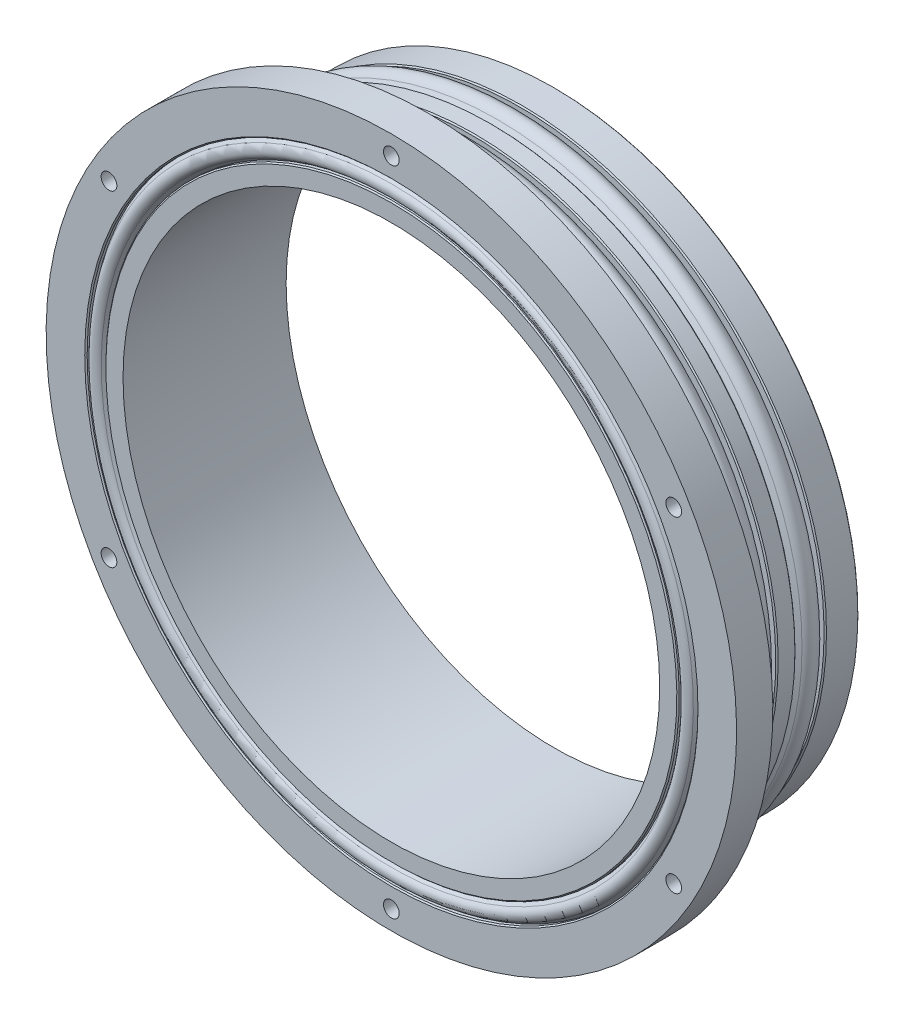
from build123d import *

# Parameters (mm, degrees)
HOLE_WIZARD_2_6_2_6_1_D     = 2.6
HOLE_WIZARD_2_6_2_6_1_DEPTH = 4
HOLE_WIZARD_2_6_2_6_2_D     = 2.6
HOLE_WIZARD_2_6_2_6_2_DEPTH = 6.526692879
HOLE_WIZARD_M80_1_D         = 88.838
HOLE_WIZARD_M80_1_DEPTH     = 27
CHAMFER_1_SIZE              = 0.2


with BuildPart() as part:
    # 草图1 → 旋转1 (revolve)
    with BuildSketch(Plane.XZ):
        with BuildLine():
            Line((47.2599, 27), (0, 27))
            Line((0, 27), (0, 0))
            Line((0, 0), (50.419, 0))
            Line((50.419, 0), (50.419, 5.587))
            Line((50.419, 5.587), (49.04105, 5.587))
            Line((49.04105, 5.587), (50.431651886, 6.547495355))
            ThreePointArc((50.431651886, 6.547495355), (51.1937, 8), (50.431651886, 9.452504645))
            Line((50.431651886, 9.452504645), (49.04105, 10.413))
            Line((49.04105, 10.413), (50.419, 10.413))
            Line((50.419, 10.413), (50.419, 13.587))
            Line((50.419, 13.587), (49.04105, 13.587))
            Line((49.04105, 13.587), (50.431651886, 14.547495355))
            ThreePointArc((50.431651886, 14.547495355), (51.1937, 16), (50.431651886, 17.452504645))
            Line((50.431651886, 17.452504645), (49.04105, 18.413))
            Line((49.04105, 18.413), (50.419, 18.413))
            Line((50.419, 18.413), (50.419, 21))
            Line((50.419, 21), (57.15, 21))
            Line((57.15, 21), (57.15, 27))
            Line((57.15, 27), (50.5587, 27))
            Line((50.5587, 27), (50.5587, 26.279170235))
            Line((50.5587, 26.279170235), (50.013761564, 27.01901462))
            ThreePointArc((50.013761564, 27.01901462), (49.0093, 27.526692879), (48.004838436, 27.01901462))
            Line((48.004838436, 27.01901462), (47.4599, 26.279170235))
            Line((47.4599, 26.279170235), (47.4599, 26.8))
            Line((47.4599, 26.8), (47.2599, 27))
        make_face()
    revolve(axis=Axis((0, 0, 27.526692879), (0, 0, -1)))

    # Ø2.6 (2.6) 直径孔1
    with Locations(Plane(origin=(0, 0, 0), x_dir=(-1, 0, 0), z_dir=(0, 0, -1))):
        with Locations((-46.99, 0), (0, 46.99), (46.99, 0), (0, -46.99)):
            Hole(HOLE_WIZARD_2_6_2_6_1_D / 2, depth=HOLE_WIZARD_2_6_2_6_1_DEPTH)

    # Ø2.6 (2.6) 直径孔2
    with Locations(Plane(origin=(0, 0, 21), x_dir=(-1, 0, 0), z_dir=(0, 0, -1))):
        with Locations((0, 53.975), (-46.743721169, 26.9875), (-46.743721169, -26.9875), (0, -53.975), (46.743721169, -26.9875), (46.743721169, 26.9875)):
            Hole(HOLE_WIZARD_2_6_2_6_2_D / 2, depth=HOLE_WIZARD_2_6_2_6_2_DEPTH)

    # M80 间隙孔1
    with Locations(Plane.XY.offset(27)):
        with Locations((0, 0)):
            Hole(HOLE_WIZARD_M80_1_D / 2, depth=HOLE_WIZARD_M80_1_DEPTH)

    # 倒角1
    chamfer_1_edges = [part.edges().sort_by_distance(p)[0] for p in [
        (-50.5587, 0, 27),
        (-50.419, 0, 18.413),
        (-50.419, 0, 13.587),
        (-50.419, 0, 10.413),
        (-50.419, 0, 5.587),
        (-50.419, 0, 0),
    ]]
    chamfer(chamfer_1_edges, length=CHAMFER_1_SIZE)


solid = part.part
